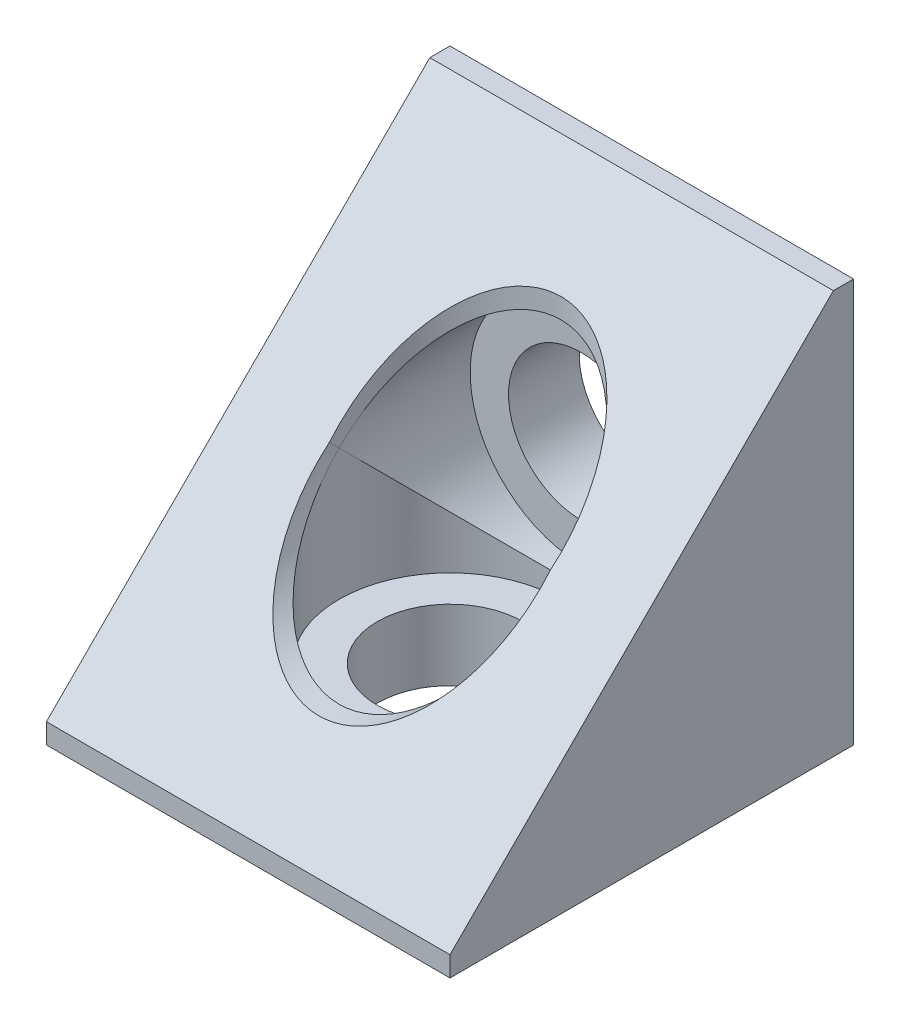
from build123d import *

# Parameters (mm, degrees)
SKETCH1_W           = 20
SKETCH1_H           = 20
SKETCH1_R           = 3.6
BOSS_EXTRUDE1_DEPTH = 10
SKETCH2_R           = 5.5
CUT_EXTRUDE1_DEPTH  = 16.5
SKETCH4_R           = 3.6
CUT_EXTRUDE2_DEPTH  = 21
SKETCH5_R           = 5.5
CUT_EXTRUDE3_DEPTH  = 16.5
CUT_EXTRUDE4_DEPTH  = 21


with BuildPart() as part:
    # Sketch1 → Boss-Extrude1 (new body, symmetric)
    with BuildSketch(Plane.XY):
        Rectangle(SKETCH1_W, SKETCH1_H)
        Circle(SKETCH1_R, mode=Mode.SUBTRACT)
    extrude(amount=BOSS_EXTRUDE1_DEPTH, both=True)

    # Sketch2 → Cut-Extrude1 (cut)
    with BuildSketch(Plane.XY.offset(10)):
        Circle(SKETCH2_R)
    extrude(amount=-CUT_EXTRUDE1_DEPTH, mode=Mode.SUBTRACT)

    # Sketch4 → Cut-Extrude2 (cut, through all)
    with BuildSketch(Plane(origin=(0, 10, 0), x_dir=(1, 0, 0), z_dir=(0, 1, 0))):
        Circle(SKETCH4_R)
    extrude(amount=-CUT_EXTRUDE2_DEPTH, mode=Mode.SUBTRACT)

    # Sketch5 → Cut-Extrude3 (cut)
    with BuildSketch(Plane(origin=(0, 10, 0), x_dir=(1, 0, 0), z_dir=(0, 1, 0))):
        Circle(SKETCH5_R)
    extrude(amount=-CUT_EXTRUDE3_DEPTH, mode=Mode.SUBTRACT)

    # Sketch6 → Cut-Extrude4 (cut, through all)
    with BuildSketch(Plane(origin=(10, 0, 0), x_dir=(0, 0, -1), z_dir=(1, 0, 0))):
        Polygon((-10, -9), (9, 10), (-10, 10), align=None)
    extrude(amount=-CUT_EXTRUDE4_DEPTH, mode=Mode.SUBTRACT)


solid = part.part
